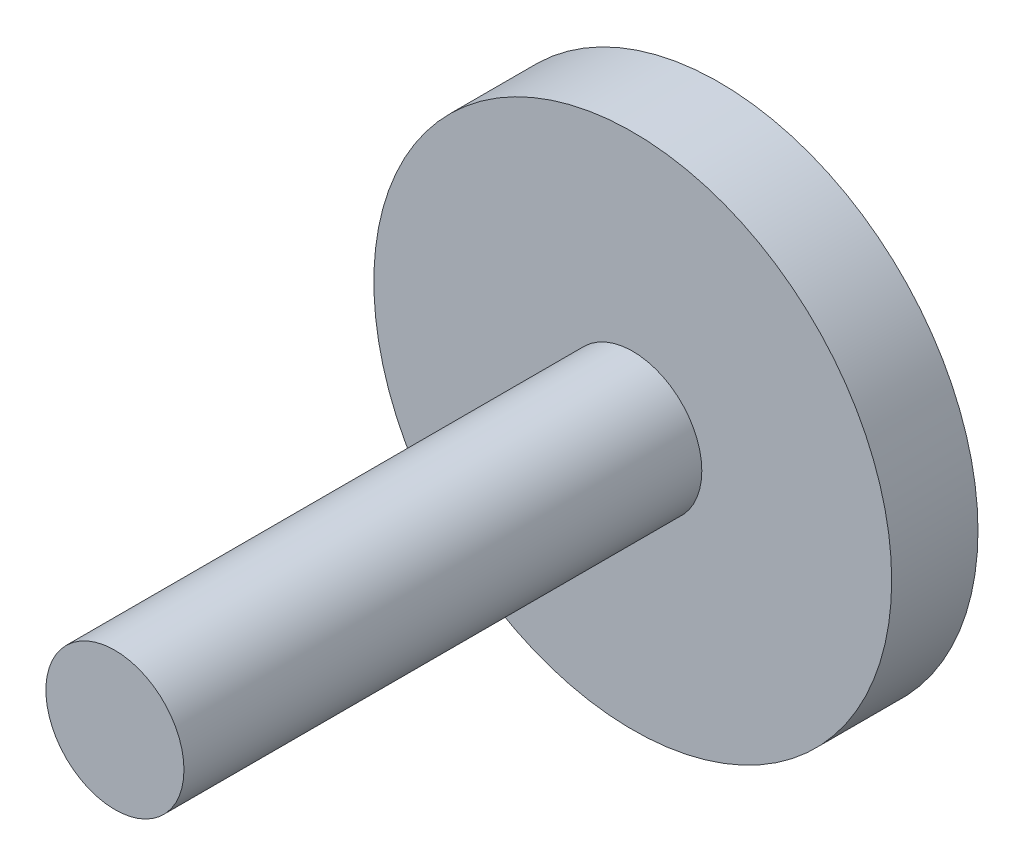
from build123d import *

# Parameters (mm, degrees)
SKETCH_1_R      = 15
EXTRUDE_1_DEPTH = 5
SKETCH_2_R      = 4
EXTRUDE_2_DEPTH = 30


with BuildPart() as part:
    # Эскиз1 → Бобышка-Вытянуть1 (new body)
    with BuildSketch(Plane.XY):
        Circle(SKETCH_1_R)
    extrude(amount=EXTRUDE_1_DEPTH)

    # Эскиз2 → Бобышка-Вытянуть2 (add)
    with BuildSketch(Plane.XY.offset(5)):
        Circle(SKETCH_2_R)
    extrude(amount=EXTRUDE_2_DEPTH)


solid = part.part
